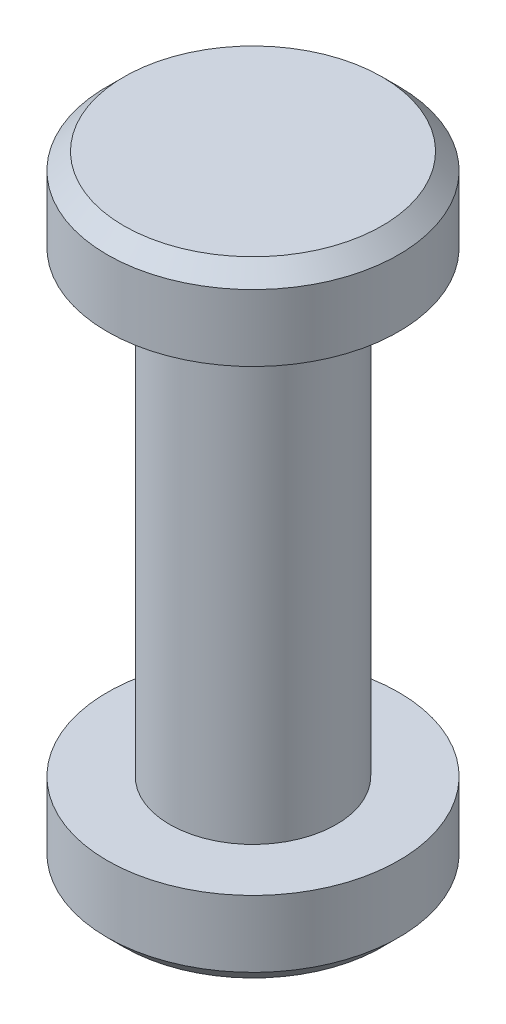
from build123d import *

# Parameters (mm, degrees)
SKETCH1_R           = 1
BOSS_EXTRUDE1_DEPTH = 5.5
SKETCH2_R           = 1.75
BOSS_EXTRUDE2_DEPTH = 1
CHAMFER1_SIZE       = 0.2
SKETCH3_R           = 1.75
BOSS_EXTRUDE3_DEPTH = 1
CHAMFER2_SIZE       = 0.2


with BuildPart() as part:
    # Sketch1 → Boss-Extrude1 (new body)
    with BuildSketch(Plane(origin=(0, 0, 0), x_dir=(1, 0, 0), z_dir=(0, 1, 0))):
        Circle(SKETCH1_R)
    extrude(amount=BOSS_EXTRUDE1_DEPTH)

    # Sketch2 → Boss-Extrude2 (add)
    with BuildSketch(Plane(origin=(0, 5.5, 0), x_dir=(1, 0, 0), z_dir=(0, 1, 0))):
        Circle(SKETCH2_R)
    extrude(amount=BOSS_EXTRUDE2_DEPTH)

    # Chamfer1
    chamfer1_edges = [part.edges().sort_by_distance(p)[0] for p in [
        (-1.75, 6.5, 0),
    ]]
    chamfer(chamfer1_edges, length=CHAMFER1_SIZE)

    # Sketch3 → Boss-Extrude3 (add)
    with BuildSketch(Plane.XZ):
        Circle(SKETCH3_R)
    extrude(amount=BOSS_EXTRUDE3_DEPTH)

    # Chamfer2
    chamfer2_edges = [part.edges().sort_by_distance(p)[0] for p in [
        (-1.75, -1, 0),
    ]]
    chamfer(chamfer2_edges, length=CHAMFER2_SIZE)


solid = part.part
